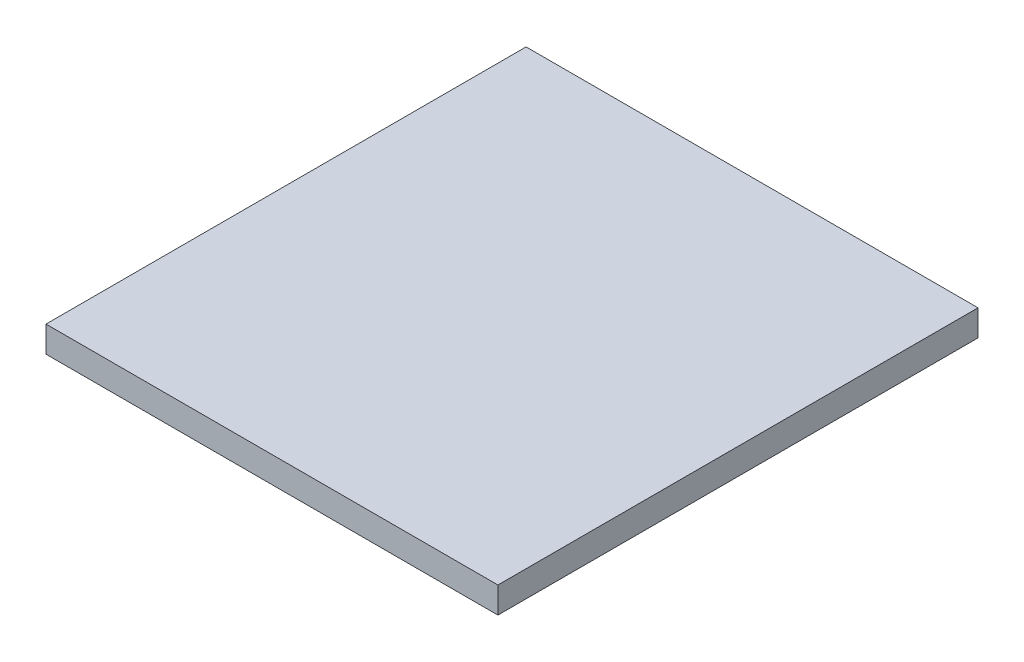
from build123d import *

# Parameters (mm, degrees)
SKETCH1_W           = 109.982
SKETCH1_H           = 116.84
BOSS_EXTRUDE1_DEPTH = 3.175


with BuildPart() as part:
    # Sketch1 → Boss-Extrude1 (new body, symmetric)
    with BuildSketch(Plane(origin=(0, 0, 0), x_dir=(1, 0, 0), z_dir=(0, 1, 0))):
        Rectangle(SKETCH1_W, SKETCH1_H)
    extrude(amount=BOSS_EXTRUDE1_DEPTH, both=True)


solid = part.part
